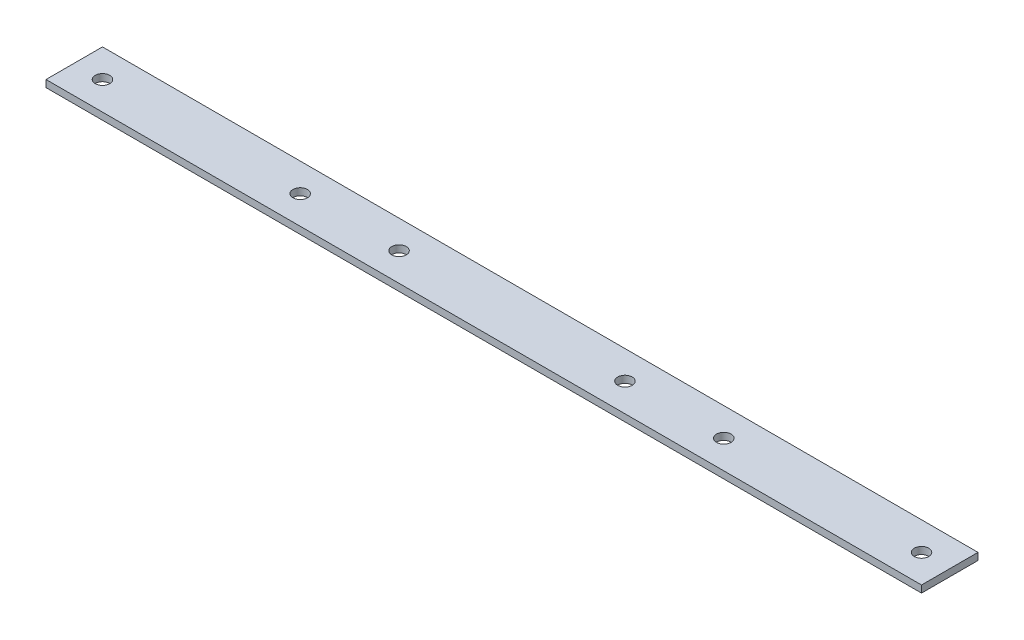
from build123d import *

# Parameters (mm, degrees)
SKETCH1_W               = 393.7
SKETCH1_H               = 25.4
BOSS_EXTRUDE1_DEPTH     = 1.5875
SKETCH2_R               = 3.2639
CUT_EXTRUDE1_DEPTH      = 1
CUT_EXTRUDE1_DEPTH_BACK = 4.175


with BuildPart() as part:
    # Sketch1 → Boss-Extrude1 (new body, symmetric)
    with BuildSketch(Plane(origin=(0, 0, 0), x_dir=(1, 0, 0), z_dir=(0, 1, 0))):
        Rectangle(SKETCH1_W, SKETCH1_H)
    extrude(amount=BOSS_EXTRUDE1_DEPTH, both=True)

    # Sketch2 → Cut-Extrude1 (cut, two sides)
    with BuildSketch(Plane(origin=(0, 1.5875, 0), x_dir=(1, 0, 0), z_dir=(0, 1, 0))) as cut_extrude1_sk:
        with Locations((-184.15, 0)):
            Circle(SKETCH2_R)
        with Locations((184.15, 0)):
            Circle(SKETCH2_R)
        with Locations((-95.25, 0)):
            Circle(SKETCH2_R)
        with Locations((95.25, 0)):
            Circle(SKETCH2_R)
        with Locations((-50.8, 0)):
            Circle(SKETCH2_R)
        with Locations((50.8, 0)):
            Circle(SKETCH2_R)
    extrude(amount=CUT_EXTRUDE1_DEPTH, mode=Mode.SUBTRACT)
    extrude(cut_extrude1_sk.sketch, amount=-CUT_EXTRUDE1_DEPTH_BACK, mode=Mode.SUBTRACT)


solid = part.part
